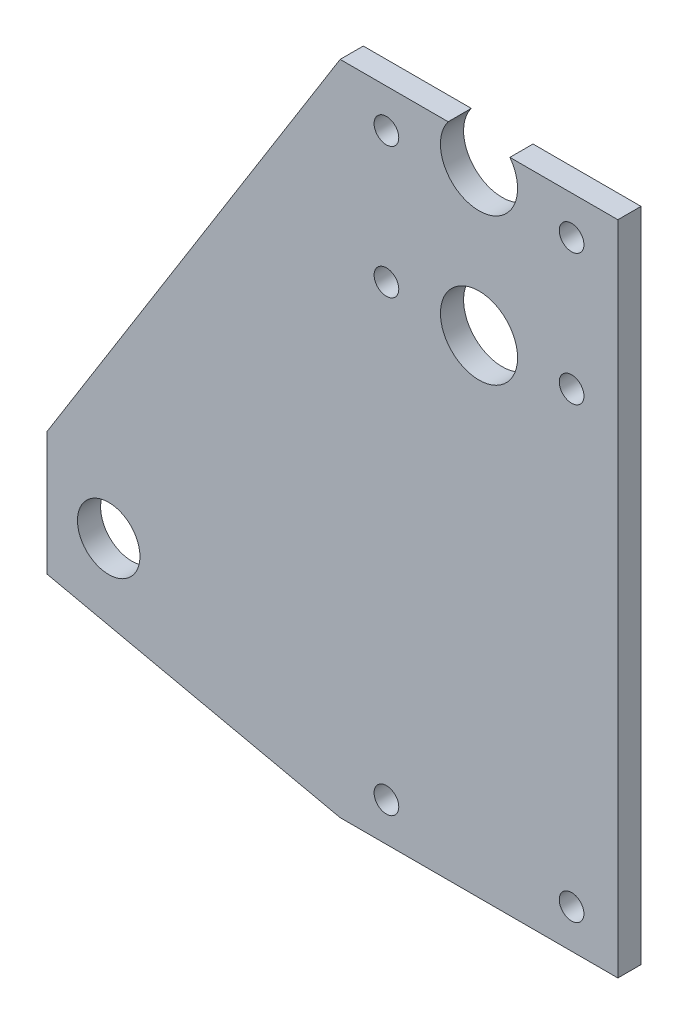
from build123d import *

# Parameters (mm, degrees)
SKETCH_1_R      = 4.05
SKETCH_1_R_2    = 1.6
SKETCH_1_R_3    = 5
EXTRUDE_1_DEPTH = 3


with BuildPart() as part:
    # ｽｹｯﾁ1 → ﾎﾞｽ - 押し出し1 (new body)
    with BuildSketch(Plane.XY):
        with BuildLine():
            Line((74, 13.65722438), (74, 98.779537634))
            Line((74, 98.779537634), (60, 98.779537634))
            ThreePointArc((60, 98.779537634), (56, 90.779537634), (52, 98.779537634))
            Line((52, 98.779537634), (38, 98.779537634))
            Line((38, 98.779537634), (0, 38))
            Line((0, 38), (0, 22))
            Line((0, 22), (38, 13.65722438))
            Line((38, 13.65722438), (74, 13.65722438))
        make_face()
        with Locations((8, 30)):
            Circle(SKETCH_1_R, mode=Mode.SUBTRACT)
        with Locations((44, 18.65722438)):
            Circle(SKETCH_1_R_2, mode=Mode.SUBTRACT)
        with Locations((68, 18.65722438)):
            Circle(SKETCH_1_R_2, mode=Mode.SUBTRACT)
        with Locations((44, 76.779537634)):
            Circle(SKETCH_1_R_2, mode=Mode.SUBTRACT)
        with Locations((56, 76.779537634)):
            Circle(SKETCH_1_R_3, mode=Mode.SUBTRACT)
        with Locations((68, 76.779537634)):
            Circle(SKETCH_1_R_2, mode=Mode.SUBTRACT)
        with Locations((44, 93.779537634)):
            Circle(SKETCH_1_R_2, mode=Mode.SUBTRACT)
        with Locations((68, 93.779537634)):
            Circle(SKETCH_1_R_2, mode=Mode.SUBTRACT)
    extrude(amount=-EXTRUDE_1_DEPTH)


solid = part.part
